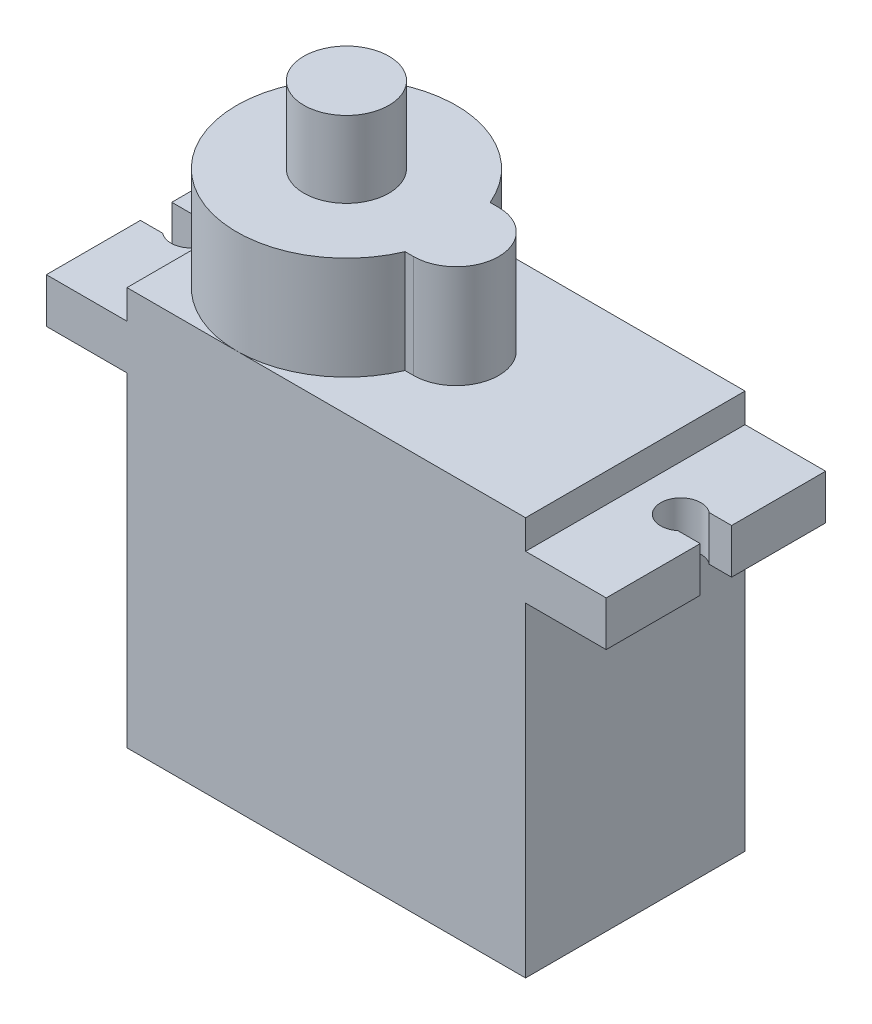
from build123d import *

# Parameters (mm, degrees)
SKETCH1_W           = 22.606
SKETCH1_H           = 12.446
BOSS_EXTRUDE1_DEPTH = 18.415
BOSS_EXTRUDE2_DEPTH = 2.54
SKETCH3_W           = 22.606
SKETCH3_H           = 12.446
BOSS_EXTRUDE3_DEPTH = 1.651
BOSS_EXTRUDE4_DEPTH = 5.842
SKETCH5_R           = 2.413
BOSS_EXTRUDE5_DEPTH = 4.318


with BuildPart() as part:
    # Sketch1 → Boss-Extrude1 (new body)
    with BuildSketch(Plane(origin=(0, 0, 0), x_dir=(1, 0, 0), z_dir=(0, 1, 0))):
        Rectangle(SKETCH1_W, SKETCH1_H)
    extrude(amount=BOSS_EXTRUDE1_DEPTH)

    # Sketch2 → Boss-Extrude2 (add)
    with BuildSketch(Plane(origin=(0, 18.415, 0), x_dir=(1, 0, 0), z_dir=(0, 1, 0))):
        with BuildLine():
            Line((15.875, -6.223), (-15.875, -6.223))
            Line((-15.875, -6.223), (-15.875, -0.889))
            Line((-15.875, -0.889), (-14.605, -0.889))
            ThreePointArc((-14.605, -0.889), (-12.74357951, 0), (-14.605, 0.889))
            Line((-14.605, 0.889), (-15.875, 0.889))
            Line((-15.875, 0.889), (-15.875, 6.223))
            Line((-15.875, 6.223), (15.875, 6.223))
            Line((15.875, 6.223), (15.875, 0.889))
            Line((15.875, 0.889), (14.605, 0.889))
            ThreePointArc((14.605, 0.889), (12.74357951, 0), (14.605, -0.889))
            Line((14.605, -0.889), (15.875, -0.889))
            Line((15.875, -0.889), (15.875, -6.223))
        make_face()
    extrude(amount=BOSS_EXTRUDE2_DEPTH)

    # Sketch3 → Boss-Extrude3 (add)
    with BuildSketch(Plane(origin=(0, 20.955, 0), x_dir=(1, 0, 0), z_dir=(0, 1, 0))):
        Rectangle(SKETCH3_W, SKETCH3_H)
    extrude(amount=BOSS_EXTRUDE3_DEPTH)

    # Sketch4 → Boss-Extrude4 (add)
    with BuildSketch(Plane(origin=(0, 22.606, 0), x_dir=(1, 0, 0), z_dir=(0, 1, 0))):
        with BuildLine():
            ThreePointArc((0.656127614, -2.413), (-6.310814133, -6.100067669), (-11.303, 0))
            ThreePointArc((-11.303, 0), (-6.310814133, 6.100067669), (0.656127614, 2.413))
            Line((0.656127614, 2.413), (1.143, 2.413))
            ThreePointArc((1.143, 2.413), (3.556, 0), (1.143, -2.413))
            Line((1.143, -2.413), (0.656127614, -2.413))
        make_face()
    extrude(amount=BOSS_EXTRUDE4_DEPTH)

    # Sketch5 → Boss-Extrude5 (add)
    with BuildSketch(Plane(origin=(0, 28.448, 0), x_dir=(1, 0, 0), z_dir=(0, 1, 0))):
        with Locations((-5.08, 0)):
            Circle(SKETCH5_R)
    extrude(amount=BOSS_EXTRUDE5_DEPTH)


solid = part.part
